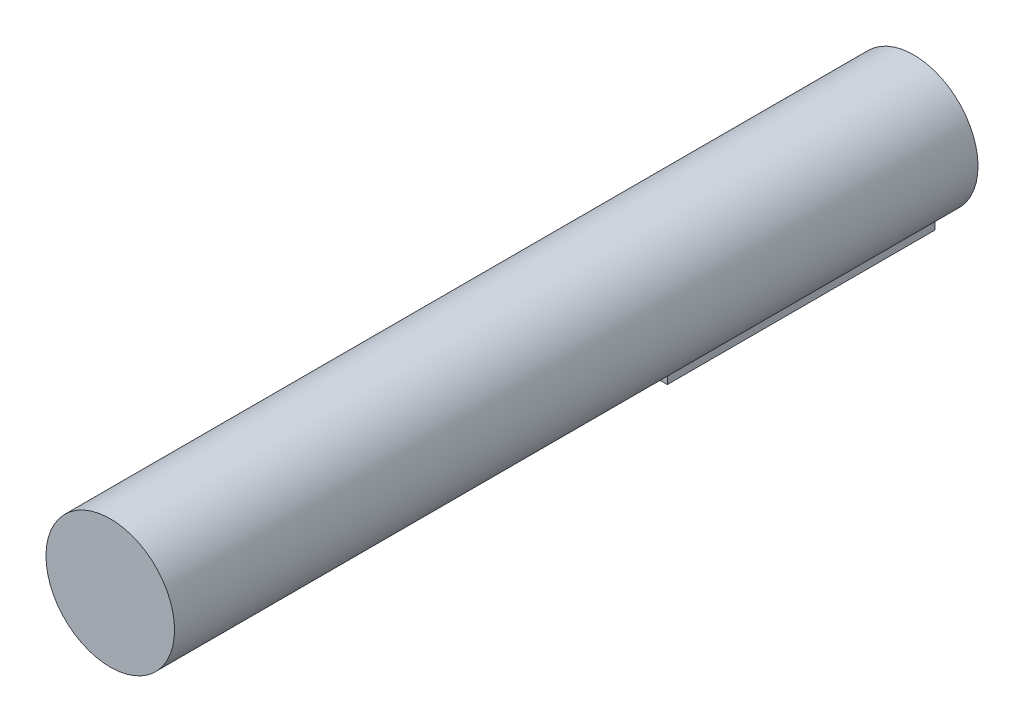
from build123d import *

# Parameters (mm, degrees)
RESSALTO_EXTRUS_O4_DEPTH = 50
RESSALTO_EXTRUS_O5_DEPTH = 150


with BuildPart() as part:
    # Esboço2 → Ressalto-extrusão4 (new body)
    with BuildSketch(Plane.XY):
        with BuildLine():
            Line((4, -14.313708499), (4, -11.313708499))
            ThreePointArc((4, -11.313708499), (0, -12), (-4, -11.313708499))
            Line((-4, -11.313708499), (-4, -14.313708499))
            Line((-4, -14.313708499), (4, -14.313708499))
        make_face()
    extrude(amount=RESSALTO_EXTRUS_O4_DEPTH)

    # Esboço2<3> → Ressalto-extrusão5 (add)
    with BuildSketch(Plane.XY):
        with BuildLine():
            ThreePointArc((-4, -11.313708499), (0, -12), (4, -11.313708499))
            ThreePointArc((4, -11.313708499), (9.797958971, -6.92820323), (12, 0))
            ThreePointArc((12, 0), (-6.92820323, 9.797958971), (-4, -11.313708499))
        make_face()
    extrude(amount=RESSALTO_EXTRUS_O5_DEPTH)


solid = part.part
